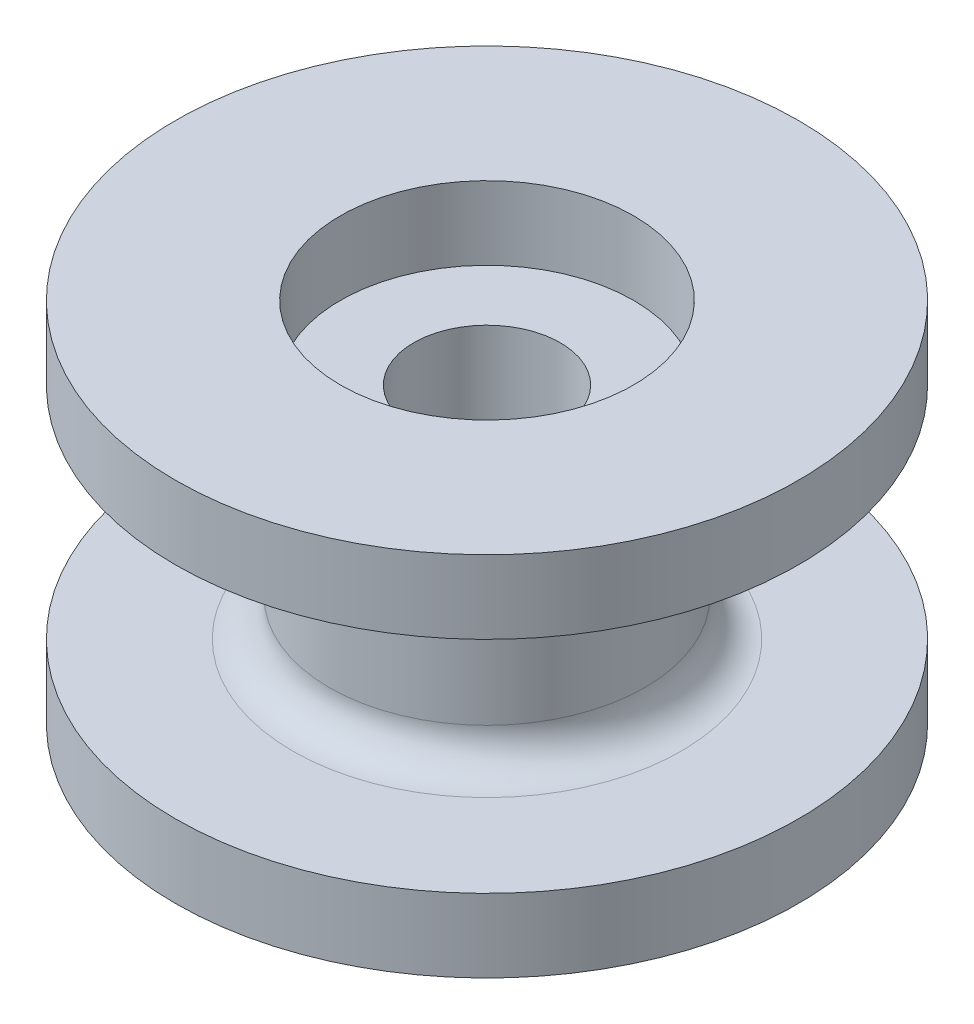
from build123d import *

# Parameters (mm, degrees)
SKETCH1_R           = 8.5
BOSS_EXTRUDE1_DEPTH = 2
SKETCH2_R           = 4.3
BOSS_EXTRUDE2_DEPTH = 6
SKETCH3_R           = 8.5
BOSS_EXTRUDE3_DEPTH = 2
SKETCH4_R           = 4
CUT_EXTRUDE1_DEPTH  = 2
SKETCH5_R           = 2
CUT_EXTRUDE2_DEPTH  = 11
FILLET1_R           = 1


with BuildPart() as part:
    # Sketch1 → Boss-Extrude1 (new body)
    with BuildSketch(Plane(origin=(0, 0, 0), x_dir=(1, 0, 0), z_dir=(0, 1, 0))):
        Circle(SKETCH1_R)
    extrude(amount=BOSS_EXTRUDE1_DEPTH)

    # Sketch2 → Boss-Extrude2 (add)
    with BuildSketch(Plane(origin=(0, 2, 0), x_dir=(1, 0, 0), z_dir=(0, 1, 0))):
        Circle(SKETCH2_R)
    extrude(amount=BOSS_EXTRUDE2_DEPTH)

    # Sketch3 → Boss-Extrude3 (add)
    with BuildSketch(Plane(origin=(0, 8, 0), x_dir=(1, 0, 0), z_dir=(0, 1, 0))):
        Circle(SKETCH3_R)
    extrude(amount=BOSS_EXTRUDE3_DEPTH)

    # Sketch4 → Cut-Extrude1 (cut)
    with BuildSketch(Plane(origin=(0, 10, 0), x_dir=(1, 0, 0), z_dir=(0, 1, 0))):
        Circle(SKETCH4_R)
    extrude(amount=-CUT_EXTRUDE1_DEPTH, mode=Mode.SUBTRACT)

    # Sketch5 → Cut-Extrude2 (cut)
    with BuildSketch(Plane(origin=(0, 8, 0), x_dir=(1, 0, 0), z_dir=(0, 1, 0))):
        Circle(SKETCH5_R)
    extrude(amount=-CUT_EXTRUDE2_DEPTH, mode=Mode.SUBTRACT)

    # Fillet1
    fillet1_edges = [part.edges().sort_by_distance(p)[0] for p in [
        (-4.3, 2, 0),
        (-4.3, 8, 0),
    ]]
    fillet(fillet1_edges, radius=FILLET1_R)


solid = part.part
